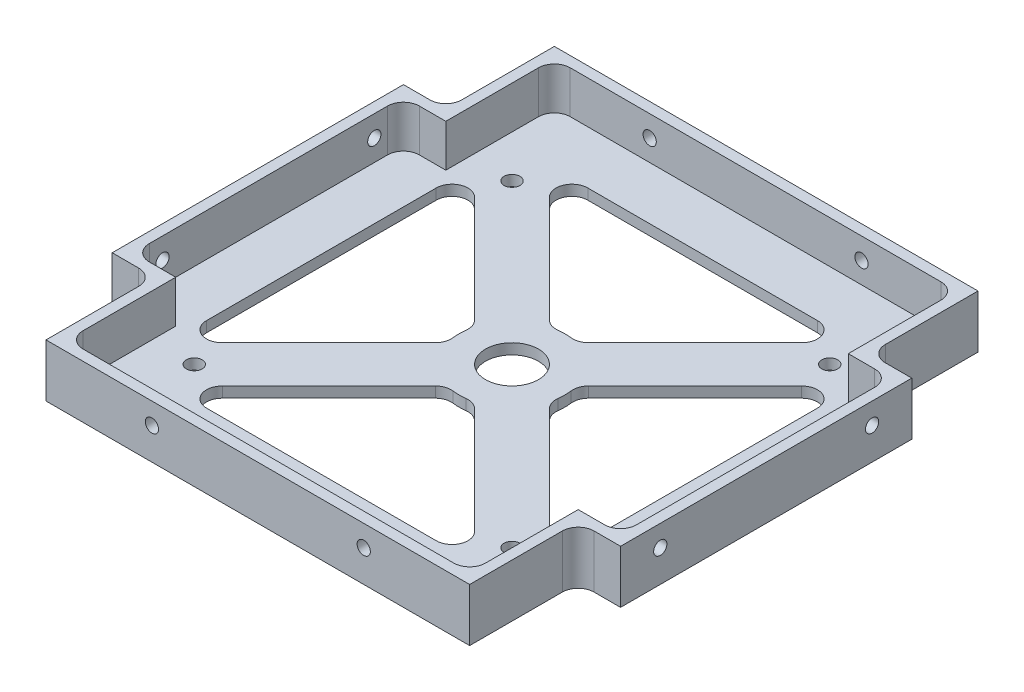
from build123d import *

# Parameters (mm, degrees)
BOSS_EXTRUDE1_DEPTH            = 10
SKETCH2_R                      = 5
CUT_EXTRUDE1_DEPTH             = 11
FILLET1_R                      = 3
CUT_EXTRUDE4_DEPTH             = 11
CUT_EXTRUDE5_DEPTH             = 8
FILLET2_R                      = 3
SKETCH7_R                      = 1.5
CUT_EXTRUDE6_DEPTH             = 10
M3X0_5_TAPPED_HOLE1_AT_2_COUNT = 2
M3X0_5_TAPPED_HOLE1_AT_2_PITCH = 40
M3X0_5_TAPPED_HOLE2_AT_2_COUNT = 2
M3X0_5_TAPPED_HOLE2_AT_2_PITCH = 40


with BuildPart() as part:
    # Sketch1 → Boss-Extrude1 (new body)
    with BuildSketch(Plane(origin=(0, 0, 0), x_dir=(1, 0, 0), z_dir=(0, 1, 0))):
        Polygon((0, 88), (0, 8), (8, 0), (88, 0), (96, 8), (96, 88), (88, 96), (8, 96), align=None)
    extrude(amount=BOSS_EXTRUDE1_DEPTH)

    # Sketch2 → Cut-Extrude1 (cut, through all)
    with BuildSketch(Plane(origin=(0, 0, 0), x_dir=(-1, 0, 0), z_dir=(0, -1, 0))):
        with BuildLine():
            Line((-45.411809549, 57.659258263), (-19.071067812, 84))
            Line((-19.071067812, 84), (-76.928932188, 84))
            Line((-76.928932188, 84), (-50.588190451, 57.659258263))
            ThreePointArc((-50.588190451, 57.659258263), (-48, 58), (-45.411809549, 57.659258263))
        make_face()
        with BuildLine():
            Line((-12, 76.928932188), (-38.340741737, 50.588190451))
            ThreePointArc((-38.340741737, 50.588190451), (-38.085551386, 49.305261922), (-38, 48))
            ThreePointArc((-38, 48), (-38.085551386, 46.694738078), (-38.340741737, 45.411809549))
            Line((-38.340741737, 45.411809549), (-12, 19.071067812))
            Line((-12, 19.071067812), (-12, 76.928932188))
        make_face()
        with BuildLine():
            Line((-19.071067812, 12), (-45.411809549, 38.340741737))
            ThreePointArc((-45.411809549, 38.340741737), (-48, 38), (-50.588190451, 38.340741737))
            Line((-50.588190451, 38.340741737), (-76.928932188, 12))
            Line((-76.928932188, 12), (-19.071067812, 12))
        make_face()
        with BuildLine():
            ThreePointArc((-57.659258263, 45.411809549), (-58, 48), (-57.659258263, 50.588190451))
            Line((-57.659258263, 50.588190451), (-84, 76.928932188))
            Line((-84, 76.928932188), (-84, 19.071067812))
            Line((-84, 19.071067812), (-57.659258263, 45.411809549))
        make_face()
        with Locations((-48, 48)):
            Circle(SKETCH2_R)
    extrude(amount=-CUT_EXTRUDE1_DEPTH, mode=Mode.SUBTRACT)

    # Fillet1
    fillet1_edges = [part.edges().sort_by_distance(p)[0] for p in [
        (50.588190451, 5, -38.340741737),
        (45.411809549, 5, -38.340741737),
        (19.071067812, 5, -12),
        (76.928932188, 5, -12),
        (38.340741737, 5, -45.411809549),
        (38.340741737, 5, -50.588190451),
        (12, 5, -76.928932188),
        (12, 5, -19.071067812),
        (57.659258263, 5, -50.588190451),
        (57.659258263, 5, -45.411809549),
        (84, 5, -19.071067812),
        (84, 5, -76.928932188),
        (45.411809549, 5, -57.659258263),
        (50.588190451, 5, -57.659258263),
        (76.928932188, 5, -84),
        (19.071067812, 5, -84),
    ]]
    fillet(fillet1_edges, radius=FILLET1_R)

    # Sketch5 → Cut-Extrude4 (cut, through all)
    with BuildSketch(Plane(origin=(0, 10, 0), x_dir=(1, 0, 0), z_dir=(0, 1, 0))):
        Polygon((8, 0), (8, 20.5), (0, 20.5), (0, 8), align=None)
        Polygon((96, 8), (88, 0), (88, 20.5), (96, 20.5), align=None)
        Polygon((96, 75.5), (88, 75.5), (88, 96), (96, 88), align=None)
        Polygon((8, 96), (8, 75.5), (0, 75.5), (0, 88), align=None)
    extrude(amount=-CUT_EXTRUDE4_DEPTH, mode=Mode.SUBTRACT)

    # Sketch6 → Cut-Extrude5 (cut)
    with BuildSketch(Plane(origin=(0, 10, 0), x_dir=(1, 0, 0), z_dir=(0, 1, 0))):
        Polygon((86, 73.5), (86, 94), (10, 94), (10, 73.5), (2, 73.5), (2, 22.5), (10, 22.5), (10, 2), (86, 2), (86, 22.5), (94, 22.5), (94, 73.5), align=None)
    extrude(amount=-CUT_EXTRUDE5_DEPTH, mode=Mode.SUBTRACT)

    # Fillet2
    fillet2_edges = [part.edges().sort_by_distance(p)[0] for p in [
        (8, 5, -75.5),
        (88, 5, -75.5),
        (88, 5, -20.5),
        (8, 5, -20.5),
        (94, 6, -73.5),
        (94, 6, -22.5),
        (86, 6, -2),
        (10, 6, -2),
        (2, 6, -22.5),
        (2, 6, -73.5),
        (10, 6, -94),
        (86, 6, -94),
    ]]
    fillet(fillet2_edges, radius=FILLET2_R)

    # Sketch7 → Cut-Extrude6 (cut)
    with BuildSketch(Plane.XZ):
        with Locations((78, -18)):
            Circle(SKETCH7_R)
        with Locations((18, -18)):
            Circle(SKETCH7_R)
        with Locations((18, -78)):
            Circle(SKETCH7_R)
        with Locations((78, -78)):
            Circle(SKETCH7_R)
    extrude(amount=-CUT_EXTRUDE6_DEPTH, mode=Mode.SUBTRACT)

    # Sketch13 → M3x0.5 Tapped Hole1 (revolve, cut)
    with BuildSketch(Plane(origin=(28, 6, 0), x_dir=(0, -1, 0), z_dir=(1, 0, 0))):
        Polygon((0, 0), (0, 8.251075774), (1.25, 7.5), (1.25, 0), align=None)
    m3x0_5_tapped_hole1 = revolve(axis=Axis((28, 6, 6.35), (0, 0, -1)), mode=Mode.SUBTRACT)

    # M3x0.5 Tapped Hole1 at 2: M3x0.5 Tapped Hole1 ×2
    with Locations(*[(i * M3X0_5_TAPPED_HOLE1_AT_2_PITCH, 0, 0) for i in range(1, M3X0_5_TAPPED_HOLE1_AT_2_COUNT)]):
        add(m3x0_5_tapped_hole1, mode=Mode.SUBTRACT)

    # Sketch15 → M3x0.5 Tapped Hole2 (revolve, cut)
    with BuildSketch(Plane(origin=(0, 6, -68), x_dir=(0, 0, 1), z_dir=(0, 1, 0))):
        Polygon((0, 0), (0, 8.251075774), (1.25, 7.5), (1.25, 0), align=None)
    m3x0_5_tapped_hole2 = revolve(axis=Axis((-6.35, 6, -68), (1, 0, 0)), mode=Mode.SUBTRACT)

    # M3x0.5 Tapped Hole2 at 2: M3x0.5 Tapped Hole2 ×2
    with Locations(*[(0, 0, i * M3X0_5_TAPPED_HOLE2_AT_2_PITCH) for i in range(1, M3X0_5_TAPPED_HOLE2_AT_2_COUNT)]):
        add(m3x0_5_tapped_hole2, mode=Mode.SUBTRACT)

    # Mirror1: M3x0.5 Tapped Hole1 across plane
    add(m3x0_5_tapped_hole1.mirror(Plane.XY.offset(-48)), mode=Mode.SUBTRACT)

    # Mirror1 copy 1 sketch → Mirror1 copy 1 (revolve, cut)
    with BuildSketch(Plane(origin=(68, 6, -96), x_dir=(0, -1, 0), z_dir=(1, 0, 0))):
        Polygon((0, 0), (0, -8.251075774), (1.25, -7.5), (1.25, 0), align=None)
    revolve(axis=Axis((68, 6, -102.35), (0, 0, -1)), mode=Mode.SUBTRACT)

    # Mirror2: M3x0.5 Tapped Hole2 across plane
    add(m3x0_5_tapped_hole2.mirror(Plane.ZY.offset(-48)), mode=Mode.SUBTRACT)

    # Mirror2 copy 1 sketch → Mirror2 copy 1 (revolve, cut)
    with BuildSketch(Plane(origin=(96, 6, -28), x_dir=(0, 0, 1), z_dir=(0, 1, 0))):
        Polygon((0, 0), (0, -8.251075774), (1.25, -7.5), (1.25, 0), align=None)
    revolve(axis=Axis((102.35, 6, -28), (1, 0, 0)), mode=Mode.SUBTRACT)


solid = part.part
